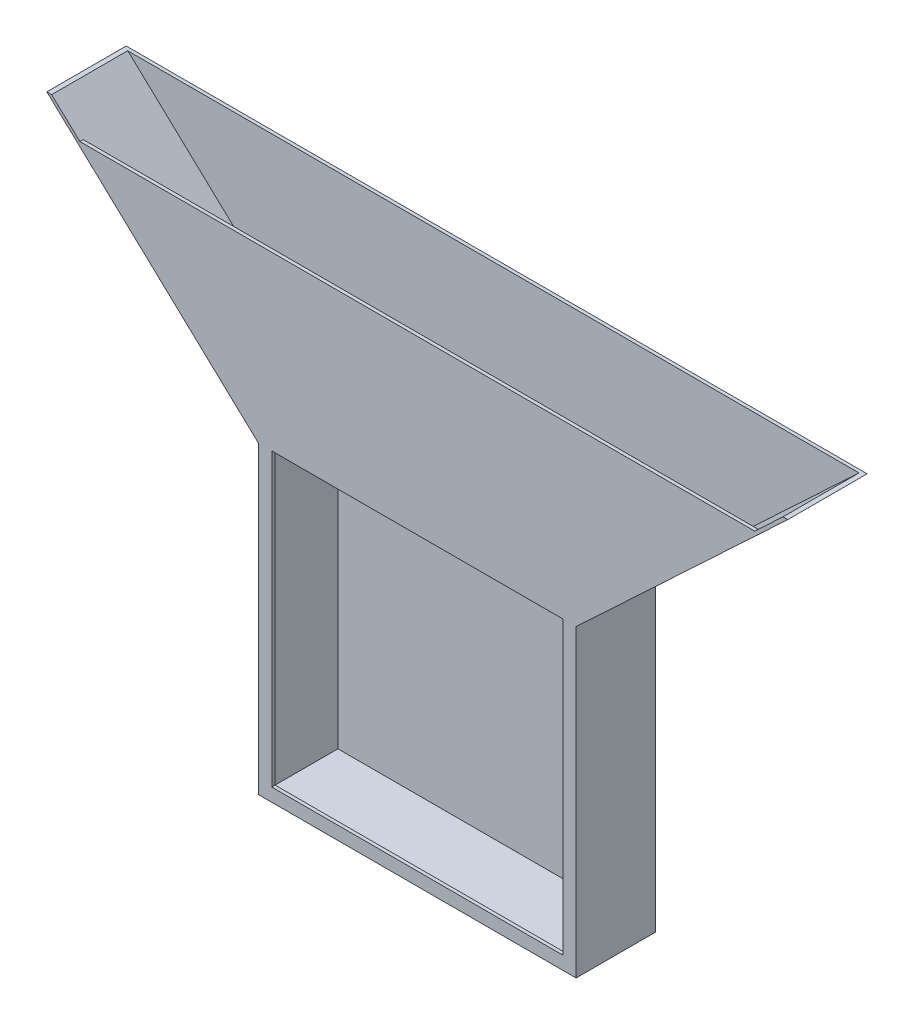
from build123d import *

# Parameters (mm, degrees)
BOSS_EXTRUDE1_DEPTH = 38.1
SHELL2_T            = -3.175
SKETCH2_W           = 279.4
SKETCH2_H           = 279.4
CUT_EXTRUDE1_DEPTH  = 73.025


with BuildPart() as part:
    # Sketch1 → Boss-Extrude1 (new body, symmetric)
    with BuildSketch(Plane.XY):
        Polygon((-152.4, 146.05), (-152.4, -146.05), (152.4, -146.05), (152.4, 146.05), (355.6, 336.55), (-355.6, 336.55), align=None)
    extrude(amount=BOSS_EXTRUDE1_DEPTH, both=True)

    # Shell2
    shell2_openings = [part.faces().sort_by_distance(p)[0] for p in [
        (0, 336.55, 0),
    ]]
    offset(amount=SHELL2_T, openings=shell2_openings, kind=Kind.INTERSECTION)

    # Sketch2 → Cut-Extrude1 (cut)
    with BuildSketch(Plane.XY.offset(38.1)):
        with Locations((0, 6.35)):
            Rectangle(SKETCH2_W, SKETCH2_H)
        Polygon((-350.957787584, 336.55), (-323.864454251, 311.15), (323.864454251, 311.15), (350.957787584, 336.55), align=None)
    extrude(amount=-CUT_EXTRUDE1_DEPTH, mode=Mode.SUBTRACT)


solid = part.part
